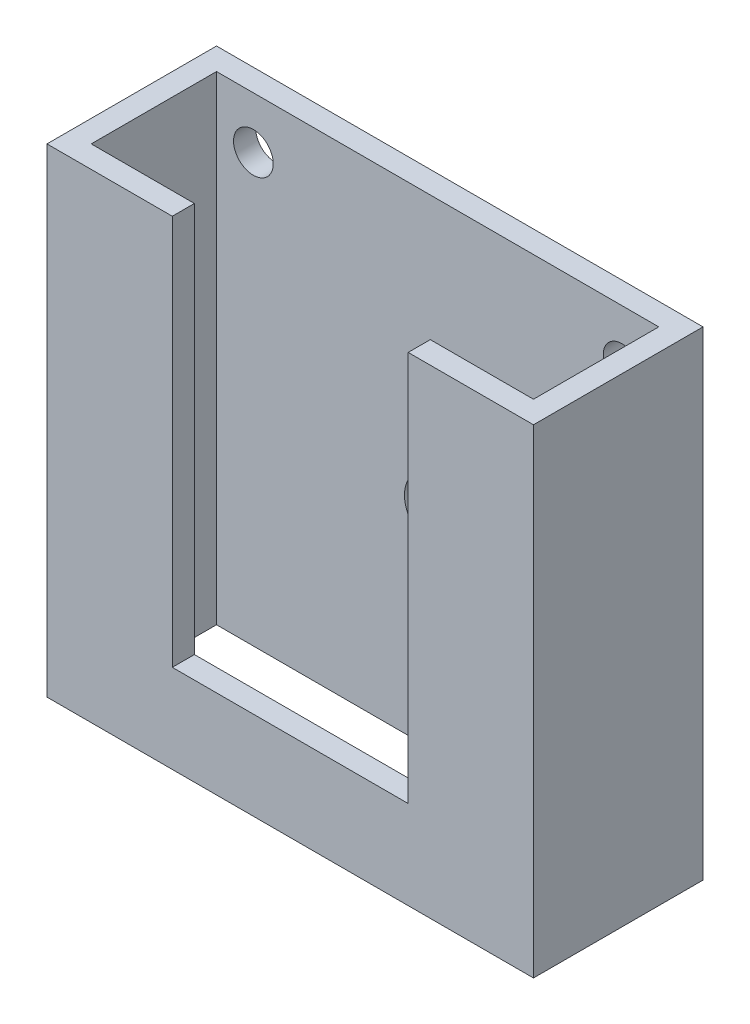
from build123d import *

# Parameters (mm, degrees)
SKETCH1_W           = 23
SKETCH1_H           = 65
BOSS_EXTRUDE1_DEPTH = 66
SKETCH2_W           = 60
SKETCH2_H           = 17
CUT_EXTRUDE1_DEPTH  = 66
CUT_EXTRUDE2_REACH  = 25
SKETCH3_W           = 32
SKETCH3_H           = 53
CUT_EXTRUDE3_REACH  = 25
SKETCH5_R           = 4.5
SKETCH5_R_2         = 2.530586218
SKETCH5_R_3         = 2.69284222


with BuildPart() as part:
    # Sketch1 → Boss-Extrude1 (new body)
    with BuildSketch(Plane(origin=(0, 0, 0), x_dir=(0, 0, -1), z_dir=(1, 0, 0))):
        with Locations((-11.5, -32.5)):
            Rectangle(SKETCH1_W, SKETCH1_H)
    extrude(amount=-BOSS_EXTRUDE1_DEPTH)

    # Sketch2 → Cut-Extrude1 (cut, through all)
    with BuildSketch(Plane(origin=(0, 0, 0), x_dir=(1, 0, 0), z_dir=(0, 1, 0))):
        with Locations((-33, -11.5)):
            Rectangle(SKETCH2_W, SKETCH2_H)
    extrude(amount=-CUT_EXTRUDE1_DEPTH, mode=Mode.SUBTRACT)

    # Sketch3 → Cut-Extrude2 (cut, up to next)
    with BuildSketch(Plane.XY.offset(23), mode=Mode.PRIVATE) as cut_extrude2_sk1:
        with Locations((-33, -26.5)):
            Rectangle(SKETCH3_W, SKETCH3_H)
    cut_extrude2_tool1 = extrude(cut_extrude2_sk1.sketch, amount=-CUT_EXTRUDE2_REACH, mode=Mode.PRIVATE) & part.part
    add(cut_extrude2_tool1.solids().sort_by_distance((-33, -26.5, 23))[0], mode=Mode.SUBTRACT)

    # Sketch5 → Cut-Extrude3 (cut, up to next)
    with BuildSketch(Plane(origin=(0, 0, 0), x_dir=(-1, 0, 0), z_dir=(0, 0, -1)), mode=Mode.PRIVATE) as cut_extrude3_sk1:
        with Locations((33, -37)):
            Circle(SKETCH5_R)
    cut_extrude3_tool1 = extrude(cut_extrude3_sk1.sketch, amount=-CUT_EXTRUDE3_REACH, mode=Mode.PRIVATE) & part.part
    add(cut_extrude3_tool1.solids().sort_by_distance((-33, -37, 0))[0], mode=Mode.SUBTRACT)
    # Sketch5 → Cut-Extrude3 (cut, up to next)
    with BuildSketch(Plane(origin=(0, 0, 0), x_dir=(-1, 0, 0), z_dir=(0, 0, -1)), mode=Mode.PRIVATE) as cut_extrude3_sk2:
        with Locations((8, -7)):
            Circle(SKETCH5_R_2)
    cut_extrude3_tool2 = extrude(cut_extrude3_sk2.sketch, amount=-CUT_EXTRUDE3_REACH, mode=Mode.PRIVATE) & part.part
    add(cut_extrude3_tool2.solids().sort_by_distance((-8, -7, 0))[0], mode=Mode.SUBTRACT)
    # Sketch5 → Cut-Extrude3 (cut, up to next)
    with BuildSketch(Plane(origin=(0, 0, 0), x_dir=(-1, 0, 0), z_dir=(0, 0, -1)), mode=Mode.PRIVATE) as cut_extrude3_sk3:
        with Locations((58, -7)):
            Circle(SKETCH5_R_3)
    cut_extrude3_tool3 = extrude(cut_extrude3_sk3.sketch, amount=-CUT_EXTRUDE3_REACH, mode=Mode.PRIVATE) & part.part
    add(cut_extrude3_tool3.solids().sort_by_distance((-58, -7, 0))[0], mode=Mode.SUBTRACT)


solid = part.part
